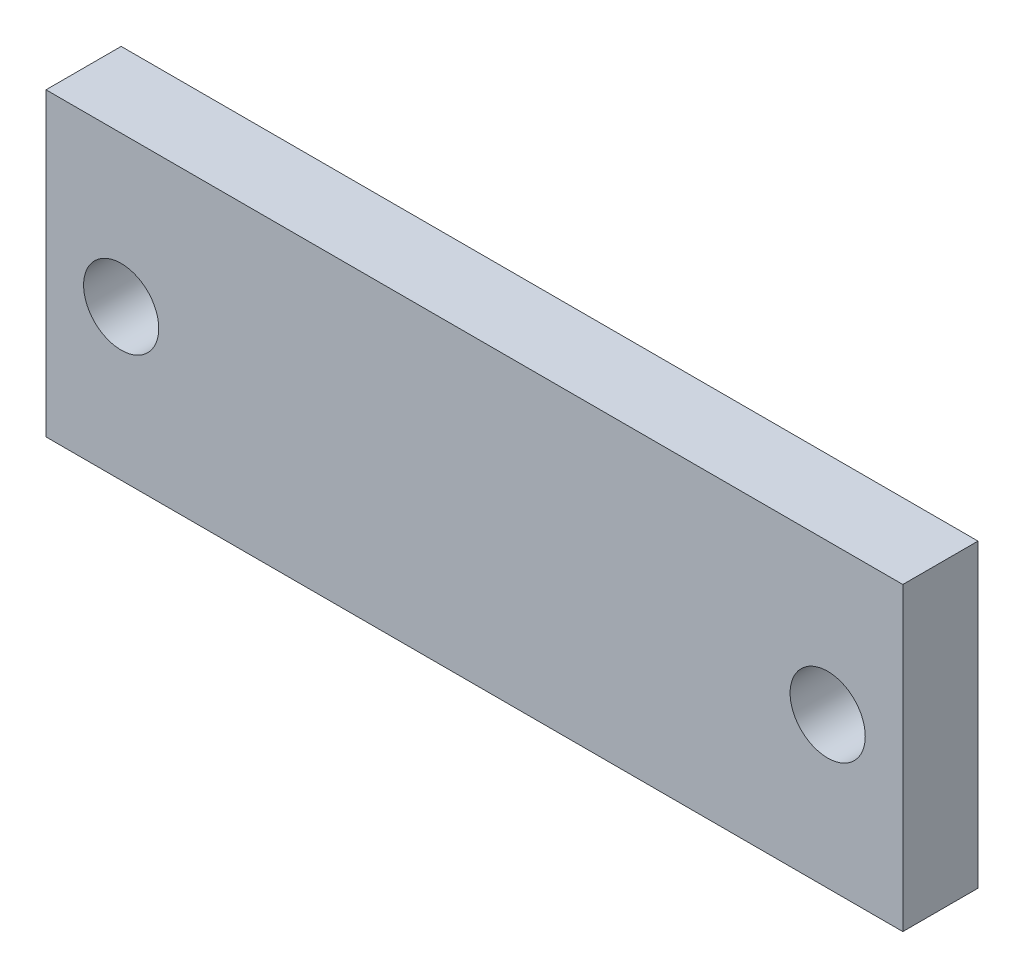
from build123d import *

# Parameters (mm, degrees)
SKETCH1_W           = 57
SKETCH1_H           = 20
SKETCH1_R           = 2.5
BOSS_EXTRUDE1_DEPTH = 5


with BuildPart() as part:
    # Sketch1 → Boss-Extrude1 (new body)
    with BuildSketch(Plane.XY):
        with Locations((28.5, 10)):
            Rectangle(SKETCH1_W, SKETCH1_H)
        with Locations((52, 10)):
            Circle(SKETCH1_R, mode=Mode.SUBTRACT)
        with Locations((5, 10)):
            Circle(SKETCH1_R, mode=Mode.SUBTRACT)
    extrude(amount=BOSS_EXTRUDE1_DEPTH)


solid = part.part
